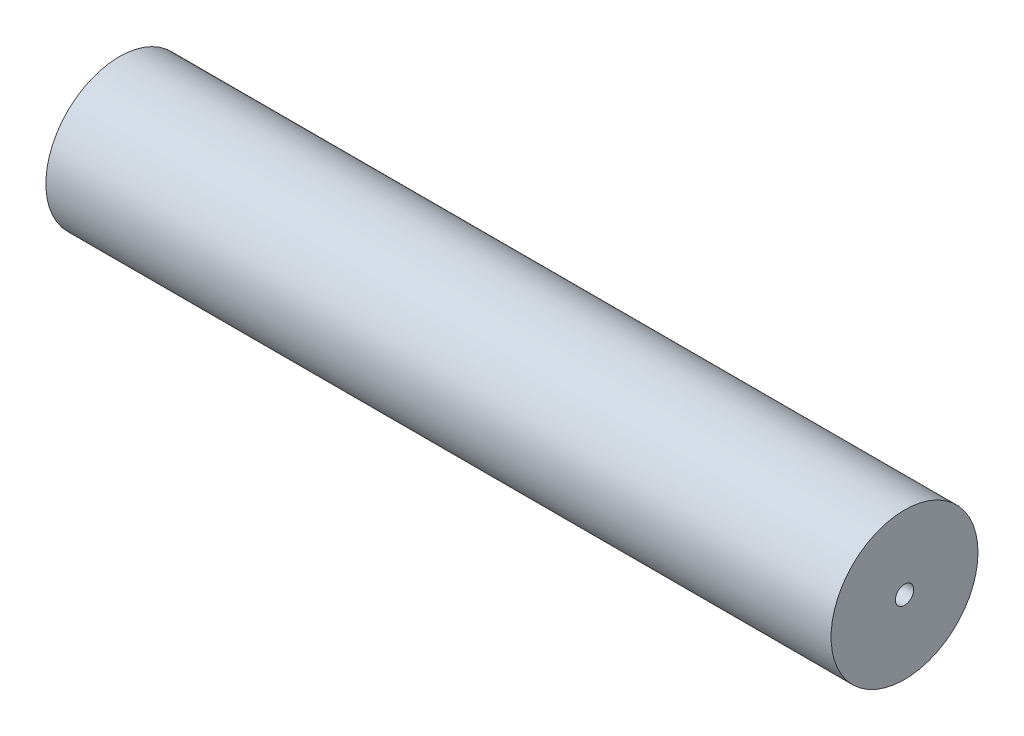
from build123d import *

# Parameters (mm, degrees)
SKETCH1_R           = 50.8
BOSS_EXTRUDE1_DEPTH = 271.4625
SKETCH2_R           = 6.35
CUT_EXTRUDE1_DEPTH  = 543.925


with BuildPart() as part:
    # Sketch1 → Boss-Extrude1 (new body, symmetric)
    with BuildSketch(Plane(origin=(0, 0, 0), x_dir=(0, 0, -1), z_dir=(1, 0, 0))):
        Circle(SKETCH1_R)
    extrude(amount=BOSS_EXTRUDE1_DEPTH, both=True)

    # Sketch2 → Cut-Extrude1 (cut, through all)
    with BuildSketch(Plane.ZY.offset(271.4625)):
        Circle(SKETCH2_R)
    extrude(amount=-CUT_EXTRUDE1_DEPTH, mode=Mode.SUBTRACT)


solid = part.part
